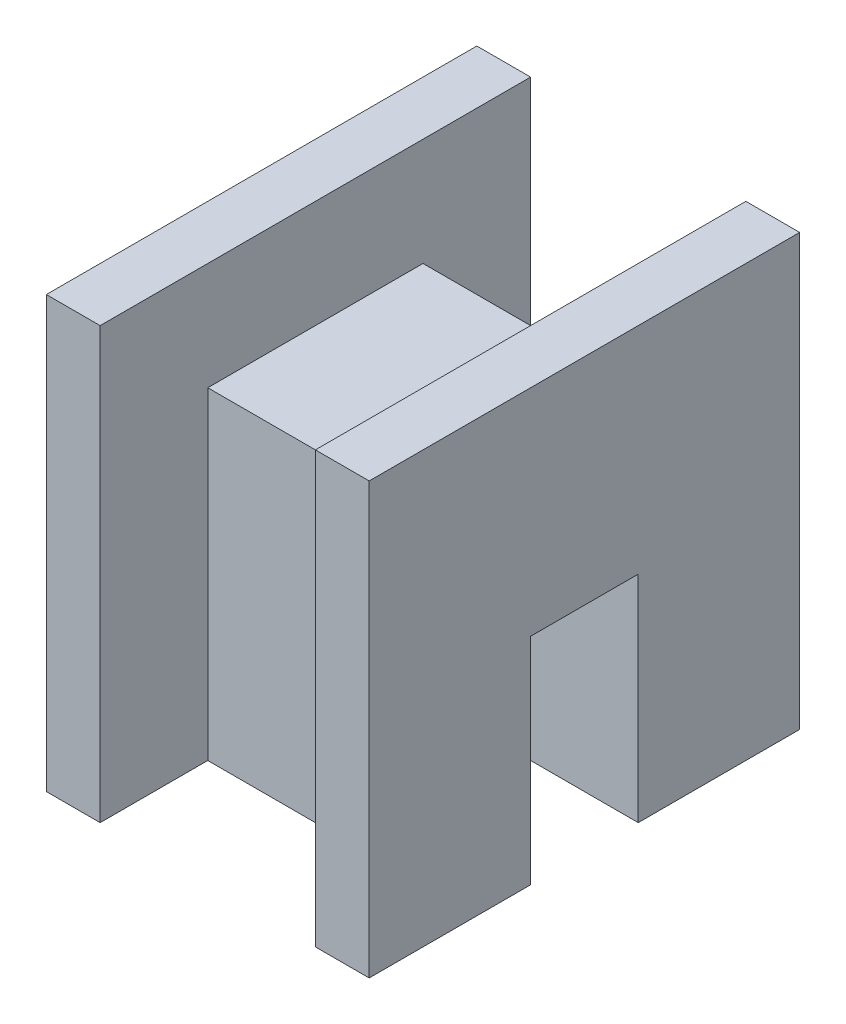
from build123d import *

# Parameters (mm, degrees)
RESSALTO_EXTRUS_O1_DEPTH = 15
CORTE_EXTRUS_O1_DEPTH    = 10


with BuildPart() as part:
    # Esboço1 → Ressalto-extrusão1 (new body, symmetric)
    with BuildSketch(Plane(origin=(0, 0, 0), x_dir=(0, 0, -1), z_dir=(1, 0, 0))):
        Polygon((-20, 0), (-20, 40), (20, 40), (20, 0), (5, 0), (5, 20), (-5, 20), (-5, 0), align=None)
    extrude(amount=RESSALTO_EXTRUS_O1_DEPTH, both=True)

    # Esboço2 → Corte-extrusão1 (cut, symmetric)
    with BuildSketch(Plane(origin=(0, 0, 0), x_dir=(0, 0, -1), z_dir=(1, 0, 0))):
        Polygon((-10, 0), (-10, 30), (10, 30), (10, 0), (20, 0), (20, 40), (-20, 40), (-20, 0), align=None)
    extrude(amount=CORTE_EXTRUS_O1_DEPTH, both=True, mode=Mode.SUBTRACT)


solid = part.part
